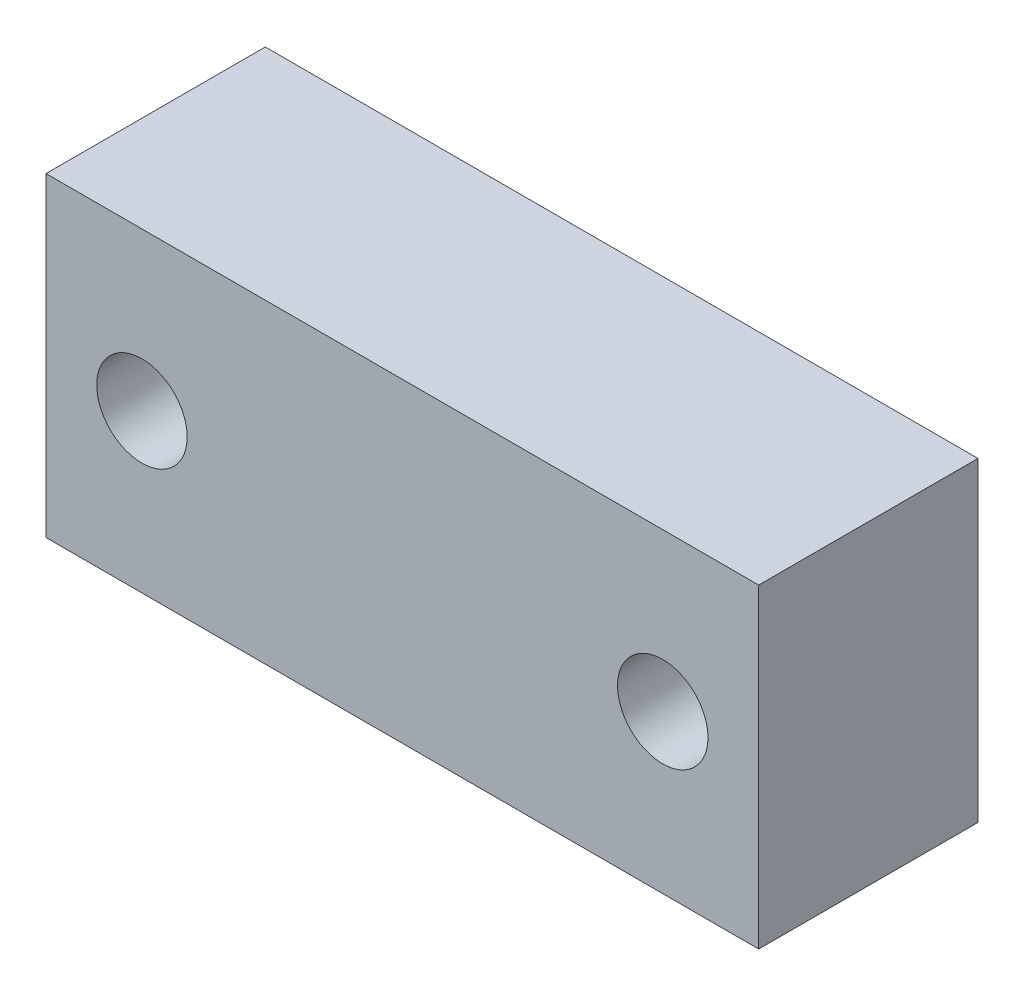
from build123d import *

# Parameters (mm, degrees)
SKETCH_1_W                  = 52
SKETCH_1_H                  = 23
EXTRUDE_1_DEPTH             = 16
HOLE_WIZARD_6_6_6_6_1_D     = 6.6
HOLE_WIZARD_6_6_6_6_1_DEPTH = 16


with BuildPart() as part:
    # 草图1 → 凸台-拉伸1 (new body)
    with BuildSketch(Plane.XY):
        Rectangle(SKETCH_1_W, SKETCH_1_H)
    extrude(amount=EXTRUDE_1_DEPTH)

    # Ø6.6 (6.6) 直径孔1
    with Locations(Plane.XY.offset(16)):
        with Locations((-19, 0), (19, 0)):
            Hole(HOLE_WIZARD_6_6_6_6_1_D / 2, depth=HOLE_WIZARD_6_6_6_6_1_DEPTH)


solid = part.part
